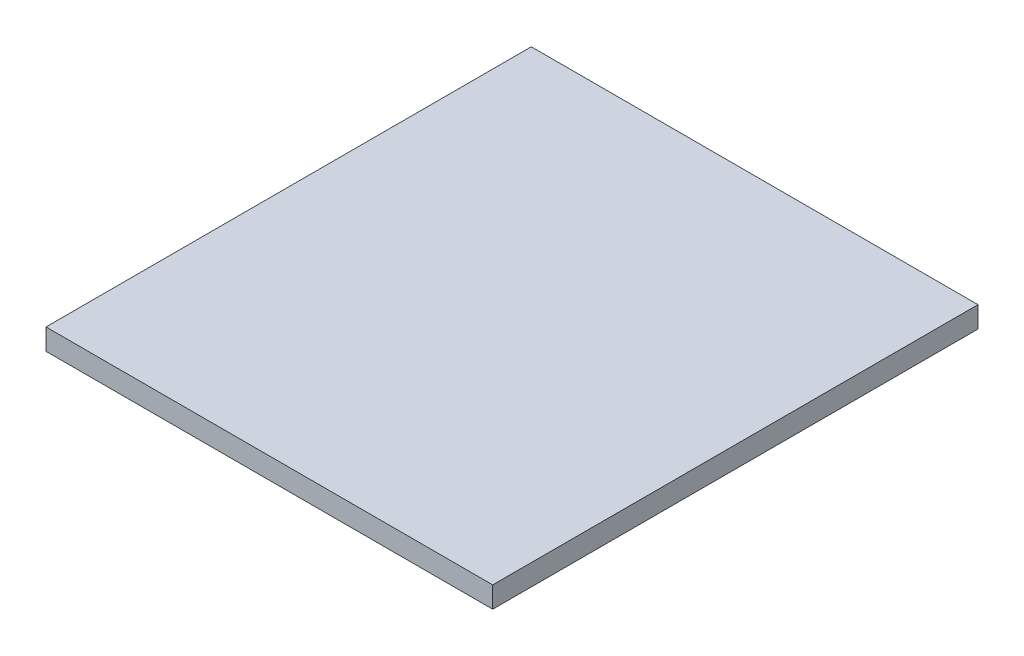
from build123d import *

# Parameters (mm, degrees)
SKETCH1_W           = 88
SKETCH1_H           = 95.6
BOSS_EXTRUDE1_DEPTH = 4.16


with BuildPart() as part:
    # Sketch1 → Boss-Extrude1 (new body)
    with BuildSketch(Plane(origin=(0, 0, 0), x_dir=(1, 0, 0), z_dir=(0, 1, 0))):
        with Locations((50, 47.8)):
            Rectangle(SKETCH1_W, SKETCH1_H)
    extrude(amount=BOSS_EXTRUDE1_DEPTH)


solid = part.part
